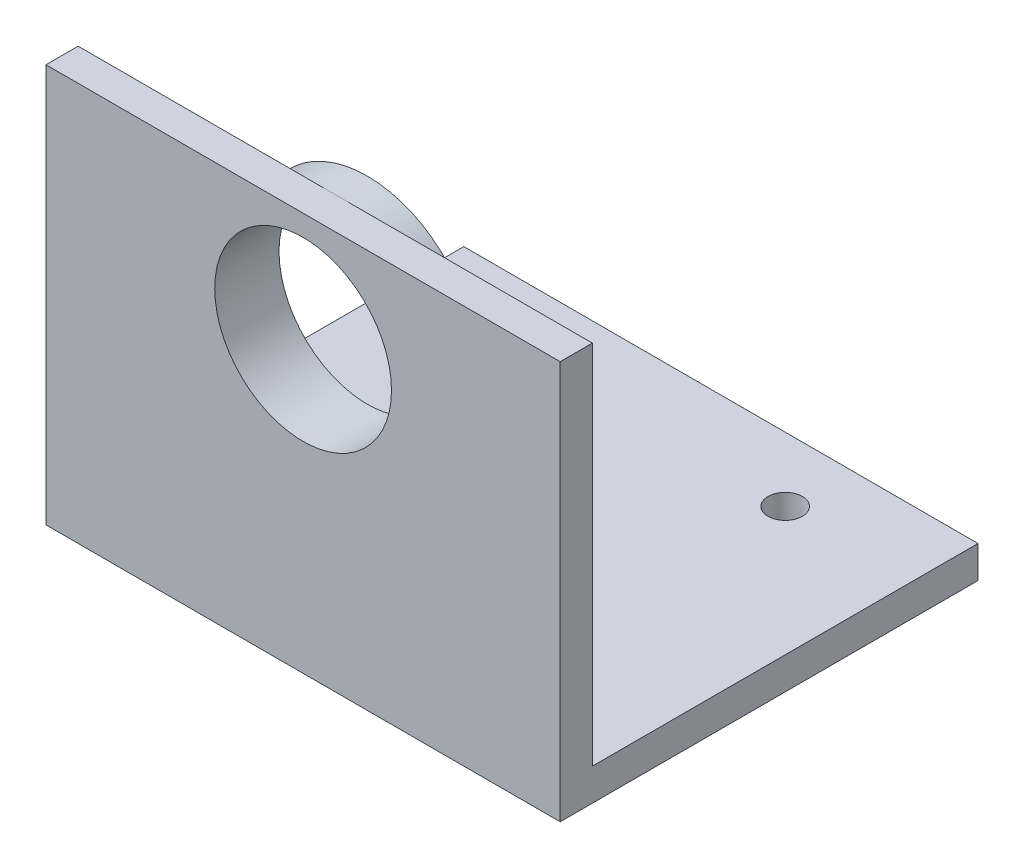
from build123d import *

# Parameters (mm, degrees)
BOSS_EXTRUDE1_DEPTH  = 3.175
M3_CLEARANCE_HOLE1_D = 3.4
SKETCH7_W            = 50.8
SKETCH7_H            = 3.175
BOSS_EXTRUDE3_DEPTH  = 39.37
BOSS_EXTRUDE4_DEPTH  = 3.175
SKETCH9_R            = 8.73125
CUT_EXTRUDE1_DEPTH   = 7.35
FILLET1_R            = 3.175


with BuildPart() as part:
    # Sketch2 → Boss-Extrude1 (new body)
    with BuildSketch(Plane(origin=(0, 0, 0), x_dir=(1, 0, 0), z_dir=(0, 1, 0))):
        Polygon((-25.4, -12.7), (25.4, -12.7), (25.4, 12.7), (25.4, 25.4), (-25.4, 25.4), (-25.4, 12.7), align=None)
    extrude(amount=BOSS_EXTRUDE1_DEPTH)

    # M3 Clearance Hole1 (through all)
    with Locations(Plane(origin=(-12.7, 0, -19.05), x_dir=(0, 0, -1), z_dir=(0, -1, 0))):
        with Locations((0, 0), (0, 25.4)):
            Hole(M3_CLEARANCE_HOLE1_D / 2)

    # Sketch7 → Boss-Extrude3 (add)
    with BuildSketch(Plane.XZ):
        with Locations((0, 14.2875)):
            Rectangle(SKETCH7_W, SKETCH7_H)
    extrude(amount=-BOSS_EXTRUDE3_DEPTH)

    # Sketch8 → Boss-Extrude4 (add)
    with BuildSketch(Plane(origin=(0, 0, 12.7), x_dir=(-1, 0, 0), z_dir=(0, 0, -1))):
        with BuildLine():
            Line((-10.795, 28.575), (-10.795, 3.175))
            Line((-10.795, 3.175), (10.795, 3.175))
            Line((10.795, 3.175), (10.795, 28.575))
            ThreePointArc((10.795, 28.575), (0, 39.37), (-10.795, 28.575))
        make_face()
    extrude(amount=BOSS_EXTRUDE4_DEPTH)

    # Sketch9 → Cut-Extrude1 (cut, through all)
    with BuildSketch(Plane(origin=(0, 0, 9.525), x_dir=(-1, 0, 0), z_dir=(0, 0, -1))):
        with Locations((0, 28.575)):
            Circle(SKETCH9_R)
    extrude(amount=-CUT_EXTRUDE1_DEPTH, mode=Mode.SUBTRACT)

    # Fillet1
    fillet1_edges = [part.edges().sort_by_distance(p)[0] for p in [
        (10.795, 3.175, 11.1125),
        (-10.795, 3.175, 11.1125),
    ]]
    fillet(fillet1_edges, radius=FILLET1_R)


solid = part.part
